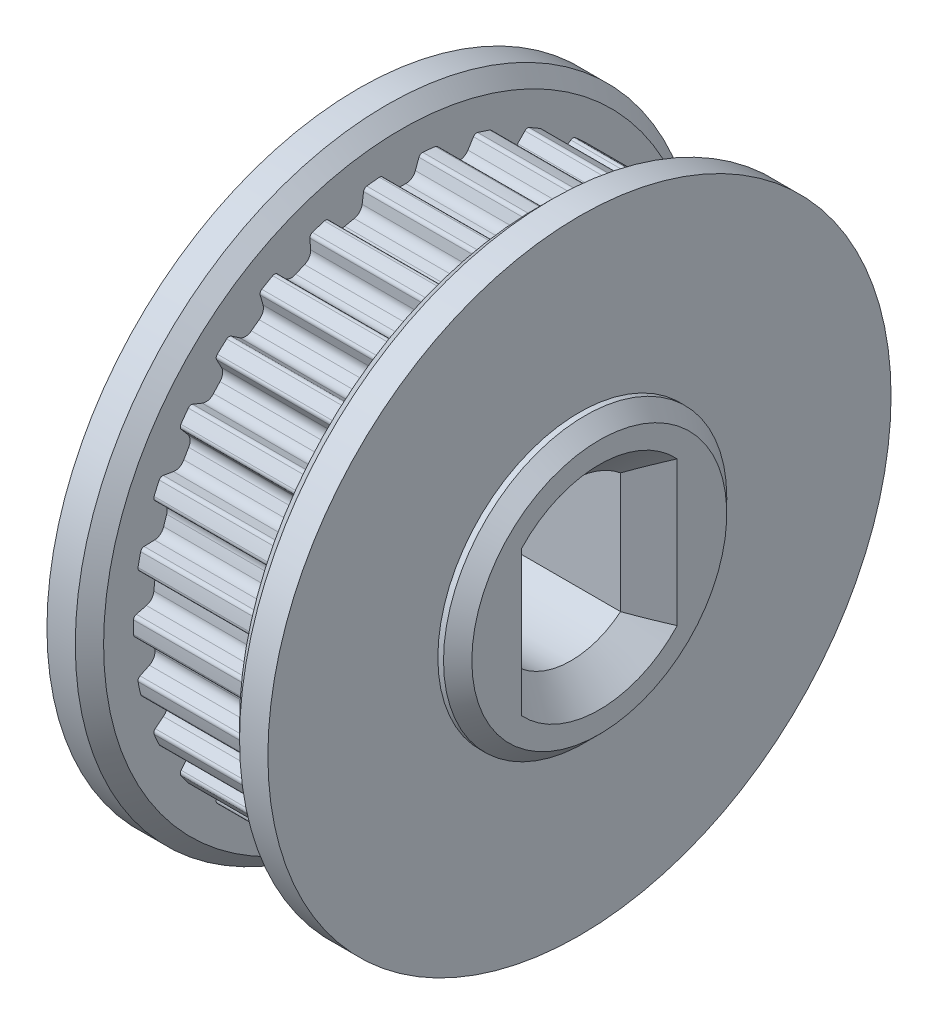
from build123d import *

# Parameters (mm, degrees)
EXTRUDE_START            = 1.5
SKETCH_7_R               = 11
SKETCH_7_R_2             = 1.75
EXTRUDE_1_DEPTH          = 1.5
CUT_EXTRUDE_3_DEPTH      = 18.727097901
CHAMFER_1_SIZE           = 1
CUT_EXTRUDE_2_REACH      = 19.059
PATTERN_CIRCULAR_3_COUNT = 30
CHAMFER_2_SIZE           = 0.5
SKETCH_9_R               = 11
SKETCH_9_R_2             = 5
EXTRUDE_2_DEPTH          = 1.5
CHAMFER_3_SIZE           = 0.5


with BuildPart() as part:
    # 草图1 → 旋转1 (revolve)
    with BuildSketch(Plane.XY):
        Polygon((0, 1.75), (0, 9.446), (4.8, 9.446), (4.8, 5), (7, 5), (7, 1.75), align=None)
    revolve(axis=Axis((0, 0, 0), (1, 0, 0)))

    # 草图7 → 凸台-拉伸1 (add)
    with BuildSketch(Plane.ZY.offset(EXTRUDE_START)):
        Circle(SKETCH_7_R)
        Circle(SKETCH_7_R_2, mode=Mode.SUBTRACT)
    extrude(amount=-EXTRUDE_1_DEPTH)

    # 草图8 → 切除-拉伸3 (cut, through all)
    with BuildSketch(Plane(origin=(7, 0, 0), x_dir=(0, 0, -1), z_dir=(1, 0, 0))):
        with BuildLine():
            Line((-1.75, 2.121320344), (-1.75, -2.121320344))
            ThreePointArc((-1.75, -2.121320344), (0, -2.75), (1.75, -2.121320344))
            Line((1.75, -2.121320344), (1.75, 2.121320344))
            ThreePointArc((1.75, 2.121320344), (0, 2.75), (-1.75, 2.121320344))
        make_face()
    extrude(amount=-CUT_EXTRUDE_3_DEPTH, mode=Mode.SUBTRACT)

    # 倒角1
    chamfer_1_edges = [part.edges().sort_by_distance(p)[0] for p in [
        (-1.5, -2.75, 0),
        (-1.5, 0, 1.75),
        (-1.5, 0, -1.75),
        (-1.5, 2.75, 0),
        (7, -2.75, 0),
        (7, 0, -1.75),
        (7, 2.75, 0),
        (7, 0, 1.75),
    ]]
    chamfer(chamfer_1_edges, length=CHAMFER_1_SIZE)

    # 草图6 → 切除-拉伸2 (cut, up to next)
    with BuildSketch(Plane(origin=(0, 0, 0), x_dir=(0, 0, -1), z_dir=(1, 0, 0)), mode=Mode.PRIVATE) as cut_extrude_2_sk1:
        with BuildLine():
            Line((0.632530376, 9.329843514), (0.50685519, 8.984553779))
            ThreePointArc((0.50685519, 8.984553779), (0.375903219, 8.815609518), (0.171122561, 8.754327677))
            ThreePointArc((0.171122561, 8.754327677), (0, 8.756), (-0.171122561, 8.754327677))
            ThreePointArc((-0.171122561, 8.754327677), (-0.375903219, 8.815609518), (-0.50685519, 8.984553779))
            Line((-0.50685519, 8.984553779), (-0.632530376, 9.329843514))
            ThreePointArc((-0.632530376, 9.329843514), (-0.684503697, 9.394805867), (-0.765221734, 9.414953622))
            ThreePointArc((-0.765221734, 9.414953622), (-0.82998998, 9.409465056), (-0.894718924, 9.403530935))
            Line((-0.894718924, 9.403530935), (-1.392814798, 10.772038102))
            ThreePointArc((-1.392814798, 10.772038102), (0, 10.861709715), (1.392814798, 10.772038102))
            Line((1.392814798, 10.772038102), (0.894718924, 9.403530935))
            ThreePointArc((0.894718924, 9.403530935), (0.82998998, 9.409465056), (0.765221734, 9.414953622))
            ThreePointArc((0.765221734, 9.414953622), (0.684503697, 9.394805867), (0.632530376, 9.329843514))
        make_face()
    cut_extrude_2_tool1 = extrude(cut_extrude_2_sk1.sketch, amount=CUT_EXTRUDE_2_REACH, mode=Mode.PRIVATE) & part.part
    cut_extrude_2 = cut_extrude_2_tool1.solids().sort_by_distance((0, 9.990305, 0))[0]
    add(cut_extrude_2, mode=Mode.SUBTRACT)

    # 阵列(圆周)3: 切除-拉伸2 ×30 about axis
    pattern_circular_3_axis = Axis((-0.35, 0, 0), (1, 0, 0))
    for i in range(1, PATTERN_CIRCULAR_3_COUNT):
        add(cut_extrude_2.rotate(pattern_circular_3_axis, i * 360 / PATTERN_CIRCULAR_3_COUNT), mode=Mode.SUBTRACT)

    # 倒角2
    chamfer_2_edges = [part.edges().sort_by_distance(p)[0] for p in [
        (0, 0, -11),
        (7, -5, 0),
    ]]
    chamfer(chamfer_2_edges, length=CHAMFER_2_SIZE)


with BuildPart() as body_2:
    # 草图9 → 凸台-拉伸2 (new body)
    with BuildSketch(Plane(origin=(4.8, 0, 0), x_dir=(0, 0, -1), z_dir=(1, 0, 0))):
        Circle(SKETCH_9_R)
        Circle(SKETCH_9_R_2, mode=Mode.SUBTRACT)
    extrude(amount=EXTRUDE_2_DEPTH)

    # 倒角3
    chamfer_3_edges = [body_2.edges().sort_by_distance(p)[0] for p in [
        (4.8, 0, 5),
        (4.8, 0, 11),
    ]]
    chamfer(chamfer_3_edges, length=CHAMFER_3_SIZE)


solid = Compound([part.part, body_2.part])
